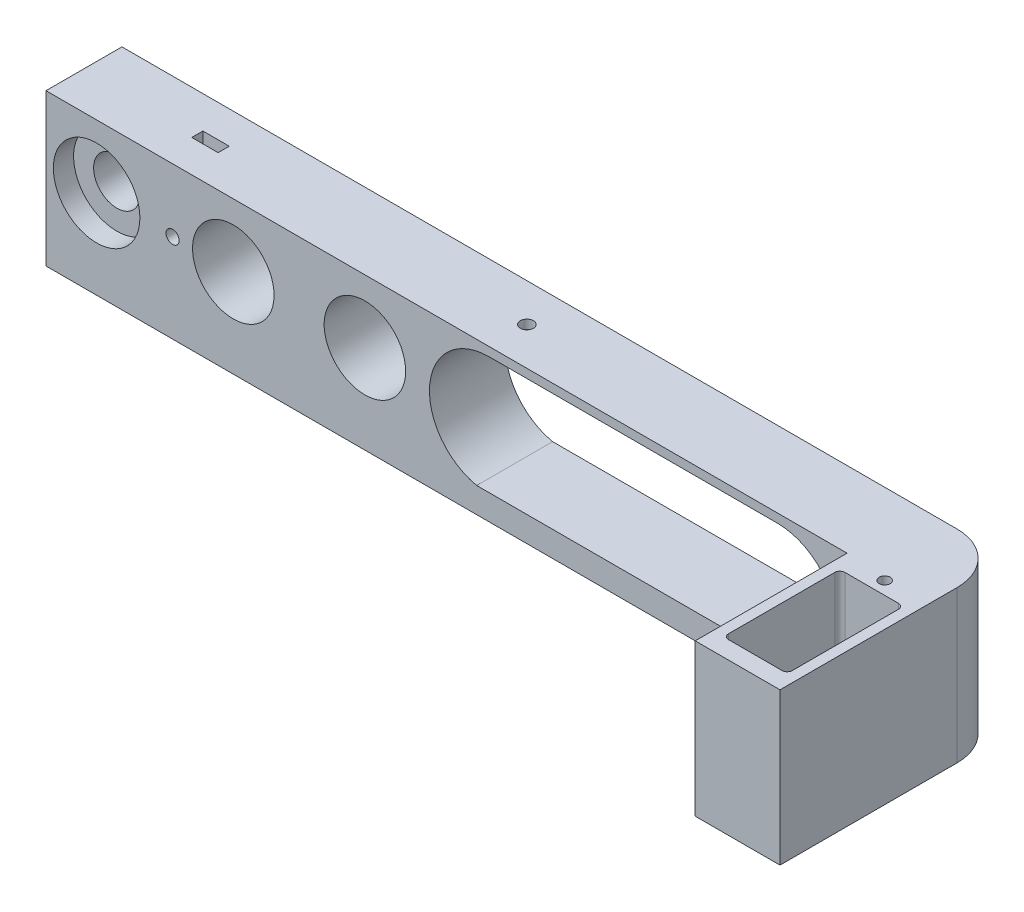
from build123d import *

# Parameters (mm, degrees)
SKETCH1_W           = 175
SKETCH1_H           = 15
BOSS_EXTRUDE1_DEPTH = 25
CUT_EXTRUDE1_REACH  = 94.229
SKETCH3_R           = 4.6
SKETCH3_R_2         = 8.05
SKETCH3_R_3         = 1.3
SKETCH3_3_R         = 8.55
SKETCH3_3_R_2       = 4.6
CUT_EXTRUDE2_DEPTH  = 4
CUT_EXTRUDE3_DEPTH  = 1.1
CUT_EXTRUDE4_REACH  = 93.31
SKETCH5_R           = 1.3
CUT_EXTRUDE6_REACH  = 94.229
SKETCH8_W           = 175
SKETCH8_H           = 15
BOSS_EXTRUDE2_DEPTH = 5
SKETCH9_W           = 16.75
SKETCH9_H           = 30
BOSS_EXTRUDE3_DEPTH = 30
SKETCH10_R          = 1.1
CUT_EXTRUDE7_DEPTH  = 30
FILLET1_R           = 10


with BuildPart() as part:
    # Sketch1 → Boss-Extrude1 (new body)
    with BuildSketch(Plane(origin=(0, 0, 0), x_dir=(1, 0, 0), z_dir=(0, 1, 0))):
        Rectangle(SKETCH1_W, SKETCH1_H)
    extrude(amount=BOSS_EXTRUDE1_DEPTH)

    # Sketch3 → Cut-Extrude1 (cut, up to next)
    with BuildSketch(Plane.XY.offset(7.5), mode=Mode.PRIVATE) as cut_extrude1_sk1:
        with Locations((-77.5, 12.5)):
            Circle(SKETCH3_R)
    cut_extrude1_tool1 = extrude(cut_extrude1_sk1.sketch, amount=-CUT_EXTRUDE1_REACH, mode=Mode.PRIVATE) & part.part
    # Sketch3 → Cut-Extrude1 (cut, up to next)
    with BuildSketch(Plane.XY.offset(7.5), mode=Mode.PRIVATE) as cut_extrude1_sk2:
        with Locations((-50.5, 12.5)):
            Circle(SKETCH3_R_2)
    cut_extrude1_tool2 = extrude(cut_extrude1_sk2.sketch, amount=-CUT_EXTRUDE1_REACH, mode=Mode.PRIVATE) & part.part
    # Sketch3 → Cut-Extrude1 (cut, up to next)
    with BuildSketch(Plane.XY.offset(7.5), mode=Mode.PRIVATE) as cut_extrude1_sk3:
        with Locations((-24.5, 12.5)):
            Circle(SKETCH3_R_2)
    cut_extrude1_tool3 = extrude(cut_extrude1_sk3.sketch, amount=-CUT_EXTRUDE1_REACH, mode=Mode.PRIVATE) & part.part
    # Sketch3 → Cut-Extrude1 (cut, up to next)
    with BuildSketch(Plane.XY.offset(7.5), mode=Mode.PRIVATE) as cut_extrude1_sk4:
        with Locations((-62.5, 12.5)):
            Circle(SKETCH3_R_3)
    cut_extrude1_tool4 = extrude(cut_extrude1_sk4.sketch, amount=-CUT_EXTRUDE1_REACH, mode=Mode.PRIVATE) & part.part
    add(cut_extrude1_tool1.solids().sort_by_distance((-77.5, 12.5, 7.5))[0], mode=Mode.SUBTRACT)
    add(cut_extrude1_tool2.solids().sort_by_distance((-50.5, 12.5, 7.5))[0], mode=Mode.SUBTRACT)
    add(cut_extrude1_tool3.solids().sort_by_distance((-24.5, 12.5, 7.5))[0], mode=Mode.SUBTRACT)
    add(cut_extrude1_tool4.solids().sort_by_distance((-62.5, 12.5, 7.5))[0], mode=Mode.SUBTRACT)

    # Sketch3_3 → Cut-Extrude2 (cut)
    with BuildSketch(Plane.XY.offset(7.5)):
        with Locations((-77.5, 12.5)):
            Circle(SKETCH3_3_R)
        with Locations((-77.5, 12.5)):
            Circle(SKETCH3_3_R_2, mode=Mode.SUBTRACT)
    extrude(amount=-CUT_EXTRUDE2_DEPTH, mode=Mode.SUBTRACT)

    # Sketch4 → Cut-Extrude3 (cut, symmetric)
    with BuildSketch(Plane.XY):
        Polygon((-65.1, 25), (-65.1, 10.9988893), (-62.5, 9.4977786), (-59.9, 10.9988893), (-59.9, 25), align=None)
    extrude(amount=CUT_EXTRUDE3_DEPTH, both=True, mode=Mode.SUBTRACT)

    # Sketch5 → Cut-Extrude4 (cut, up to next)
    with BuildSketch(Plane(origin=(0, 25, 0), x_dir=(1, 0, 0), z_dir=(0, 1, 0)), mode=Mode.PRIVATE) as cut_extrude4_sk1:
        Circle(SKETCH5_R)
    cut_extrude4_tool1 = extrude(cut_extrude4_sk1.sketch, amount=-CUT_EXTRUDE4_REACH, mode=Mode.PRIVATE) & part.part
    add(cut_extrude4_tool1.solids().sort_by_distance((0, 25, 0))[0], mode=Mode.SUBTRACT)

    # Sketch6 → Cut-Extrude6 (cut, up to next)
    with BuildSketch(Plane.XY.offset(7.5), mode=Mode.PRIVATE) as cut_extrude6_sk1:
        with BuildLine():
            Line((-2.41091269, 0), (59.41091269, 0))
            ThreePointArc((59.41091269, 0), (68.687332887, 12.711919964), (57, 23.25))
            Line((57, 23.25), (0, 23.25))
            ThreePointArc((0, 23.25), (-11.687332887, 12.711919964), (-2.41091269, 0))
        make_face()
    cut_extrude6_tool1 = extrude(cut_extrude6_sk1.sketch, amount=-CUT_EXTRUDE6_REACH, mode=Mode.PRIVATE) & part.part
    add(cut_extrude6_tool1.solids().sort_by_distance((28.5, 11.599534, 7.5))[0], mode=Mode.SUBTRACT)

    # Sketch8 → Boss-Extrude2 (add)
    with BuildSketch(Plane.XZ):
        Rectangle(SKETCH8_W, SKETCH8_H)
    extrude(amount=BOSS_EXTRUDE2_DEPTH)

    # Sketch9 → Boss-Extrude3 (add)
    with BuildSketch(Plane.XY.offset(7.5)):
        with Locations((79.125, 10)):
            Rectangle(SKETCH9_W, SKETCH9_H)
    extrude(amount=BOSS_EXTRUDE3_DEPTH)

    # Sketch10 → Cut-Extrude7 (cut)
    with BuildSketch(Plane(origin=(0, 25, 0), x_dir=(1, 0, 0), z_dir=(0, 1, 0))):
        with Locations((79.125, -8.45)):
            Circle(SKETCH10_R)
        with BuildLine():
            Line((73.825, -34), (84.425, -34))
            ThreePointArc((84.425, -34), (85.132106781, -33.707106781), (85.425, -33))
            Line((85.425, -33), (85.425, -12))
            ThreePointArc((85.425, -12), (85.132106781, -11.292893219), (84.425, -11))
            Line((84.425, -11), (73.825, -11))
            ThreePointArc((73.825, -11), (73.117893219, -11.292893219), (72.825, -12))
            Line((72.825, -12), (72.825, -33))
            ThreePointArc((72.825, -33), (73.117893219, -33.707106781), (73.825, -34))
        make_face()
    extrude(amount=-CUT_EXTRUDE7_DEPTH, mode=Mode.SUBTRACT)

    # Fillet1
    fillet1_edges = [part.edges().sort_by_distance(p)[0] for p in [
        (87.5, 10, -7.5),
    ]]
    fillet(fillet1_edges, radius=FILLET1_R)


solid = part.part
